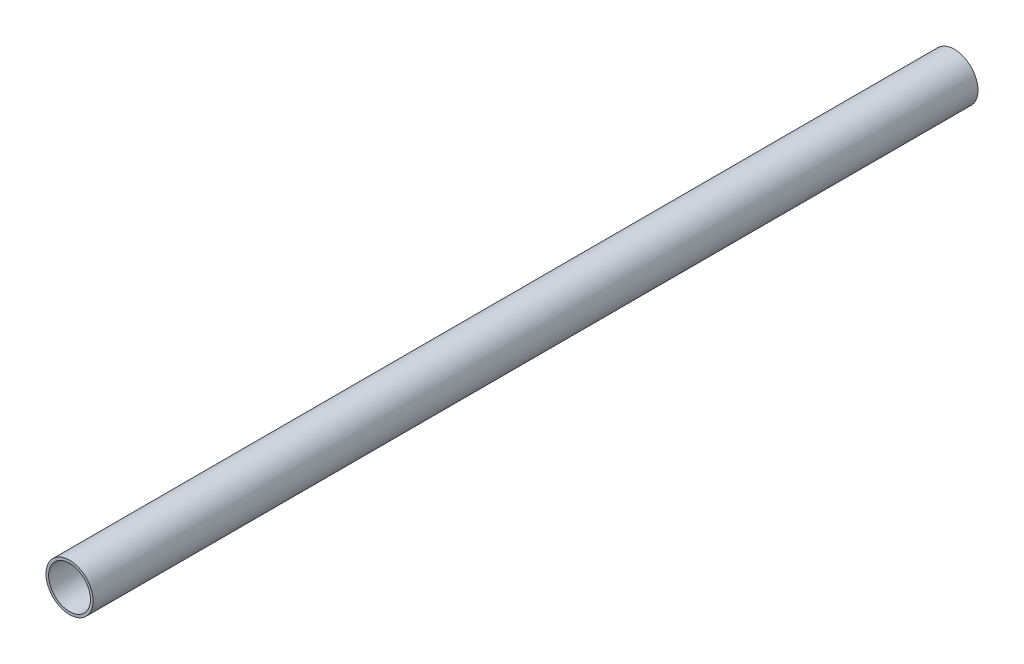
from build123d import *

# Parameters (mm, degrees)
SKETCH1_R           = 16.59255
SKETCH1_R_2         = 14.72565
BOSS_EXTRUDE1_DEPTH = 622.3


with BuildPart() as part:
    # Sketch1 → Boss-Extrude1 (new body)
    with BuildSketch(Plane.XY):
        Circle(SKETCH1_R)
        Circle(SKETCH1_R_2, mode=Mode.SUBTRACT)
    extrude(amount=BOSS_EXTRUDE1_DEPTH)


solid = part.part
